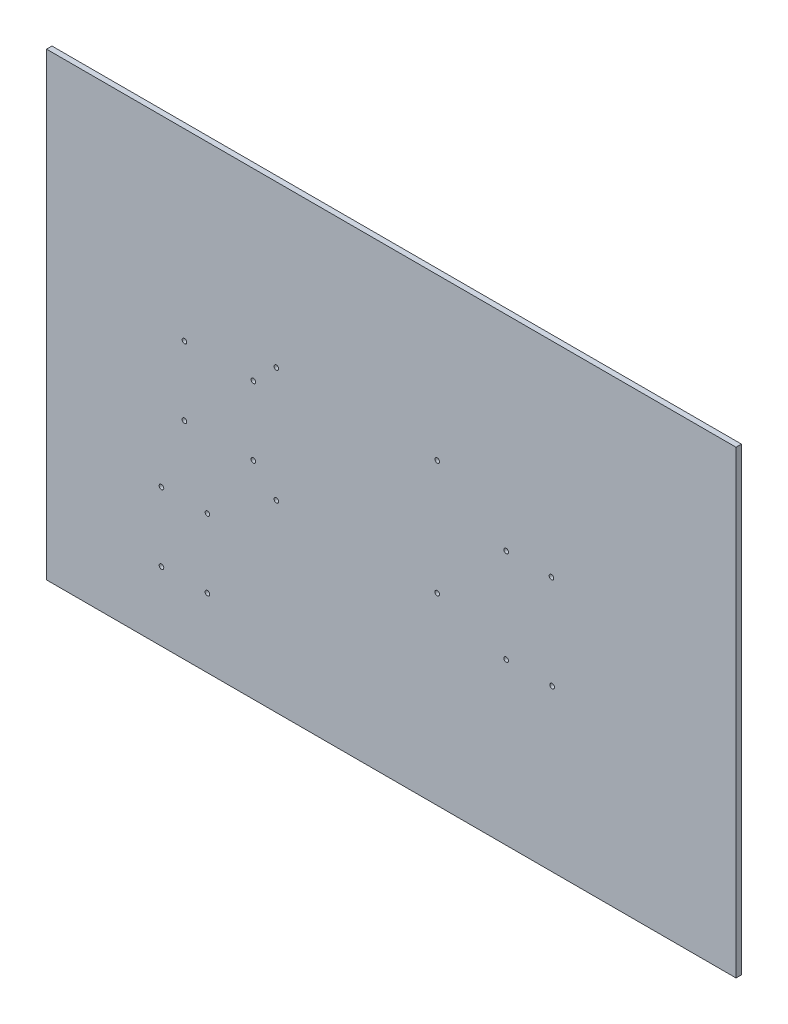
from build123d import *

# Parameters (mm, degrees)
SKETCH2_W           = 762
SKETCH2_H           = 508
SKETCH2_R           = 2.555
BOSS_EXTRUDE1_DEPTH = 6


with BuildPart() as part:
    # Sketch2 → Boss-Extrude1 (new body)
    with BuildSketch(Plane.XY):
        Rectangle(SKETCH2_W, SKETCH2_H)
        with Locations((-228.6, 50.8)):
            Circle(SKETCH2_R, mode=Mode.SUBTRACT)
        with Locations((-228.6, -25.4)):
            Circle(SKETCH2_R, mode=Mode.SUBTRACT)
        with Locations((-152.4, 50.8)):
            Circle(SKETCH2_R, mode=Mode.SUBTRACT)
        with Locations((-152.4, -25.4)):
            Circle(SKETCH2_R, mode=Mode.SUBTRACT)
        with Locations((-127, 76.2)):
            Circle(SKETCH2_R, mode=Mode.SUBTRACT)
        with Locations((-127, -50.8)):
            Circle(SKETCH2_R, mode=Mode.SUBTRACT)
        with Locations((50.8, 76.2)):
            Circle(SKETCH2_R, mode=Mode.SUBTRACT)
        with Locations((50.8, -50.8)):
            Circle(SKETCH2_R, mode=Mode.SUBTRACT)
        with Locations((-254, -177.8)):
            Circle(SKETCH2_R, mode=Mode.SUBTRACT)
        with Locations((-203.2, -177.8)):
            Circle(SKETCH2_R, mode=Mode.SUBTRACT)
        with Locations((-254, -101.6)):
            Circle(SKETCH2_R, mode=Mode.SUBTRACT)
        with Locations((-203.2, -101.6)):
            Circle(SKETCH2_R, mode=Mode.SUBTRACT)
        with Locations((127, -76.2)):
            Circle(SKETCH2_R, mode=Mode.SUBTRACT)
        with Locations((177.8, -76.2)):
            Circle(SKETCH2_R, mode=Mode.SUBTRACT)
        with Locations((127, 27.7)):
            Circle(SKETCH2_R, mode=Mode.SUBTRACT)
        with Locations((177, 27.69692007)):
            Circle(SKETCH2_R, mode=Mode.SUBTRACT)
    extrude(amount=BOSS_EXTRUDE1_DEPTH)


solid = part.part
